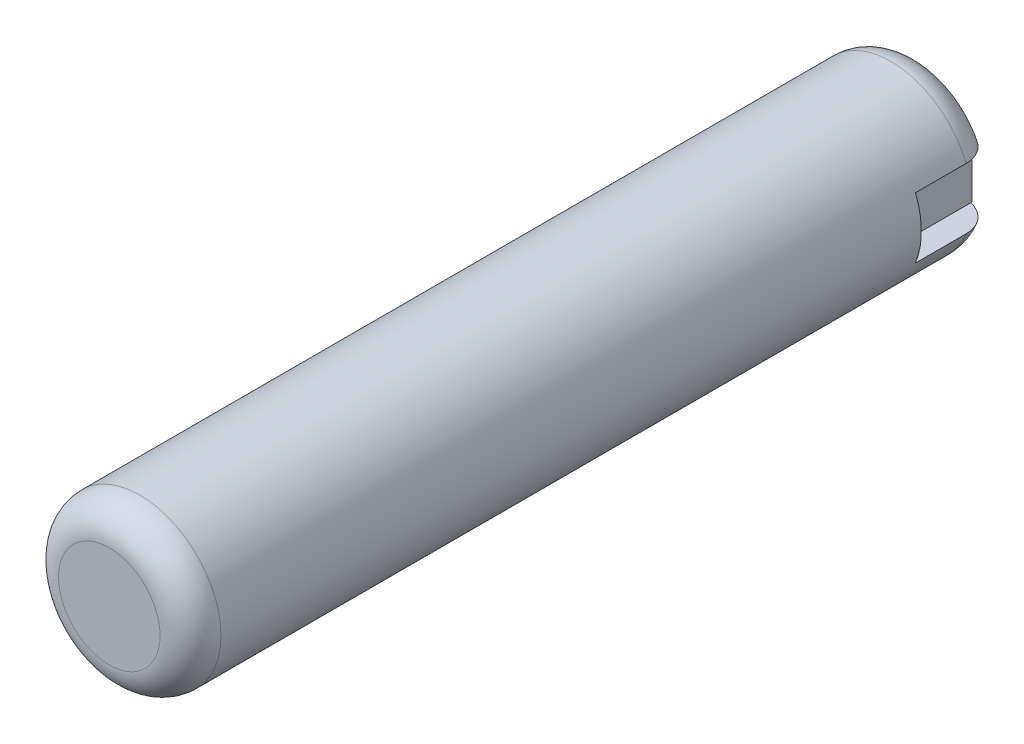
from build123d import *

# Parameters (mm, degrees)
ESQUISSE1_R             = 4
BOSS_EXTRU_1_DEPTH      = 20
CONG_1_R                = 1.5
ESQUISSE2_W             = 4
ESQUISSE2_H             = 3
ENL_V_MAT_EXTRU_1_DEPTH = 5
ESQUISSE3_W             = 5
ESQUISSE3_H             = 3
BOSS_EXTRU_2_DEPTH      = 4


with BuildPart() as part:
    # Esquisse1 → Boss.-Extru.1 (new body, symmetric)
    with BuildSketch(Plane.XY):
        Circle(ESQUISSE1_R)
    extrude(amount=BOSS_EXTRU_1_DEPTH, both=True)

    # Congé1
    cong_1_edges = [part.edges().sort_by_distance(p)[0] for p in [
        (-4, 0, -20),
        (-4, 0, 20),
    ]]
    fillet(cong_1_edges, radius=CONG_1_R)

    # Esquisse2 → Enlèv. mat.-Extru.1 (cut, symmetric)
    with BuildSketch(Plane(origin=(0, 0, 0), x_dir=(0, 0, -1), z_dir=(1, 0, 0))):
        with Locations((18, 0)):
            Rectangle(ESQUISSE2_W, ESQUISSE2_H)
    extrude(amount=ENL_V_MAT_EXTRU_1_DEPTH, both=True, mode=Mode.SUBTRACT)


with BuildPart() as body_2:
    # Esquisse3 → Boss.-Extru.2 (new body)
    with BuildSketch(Plane(origin=(0, 0, -16), x_dir=(-1, 0, 0), z_dir=(0, 0, -1))):
        Rectangle(ESQUISSE3_W, ESQUISSE3_H)
    extrude(amount=BOSS_EXTRU_2_DEPTH)


solid = Compound([part.part, body_2.part])
